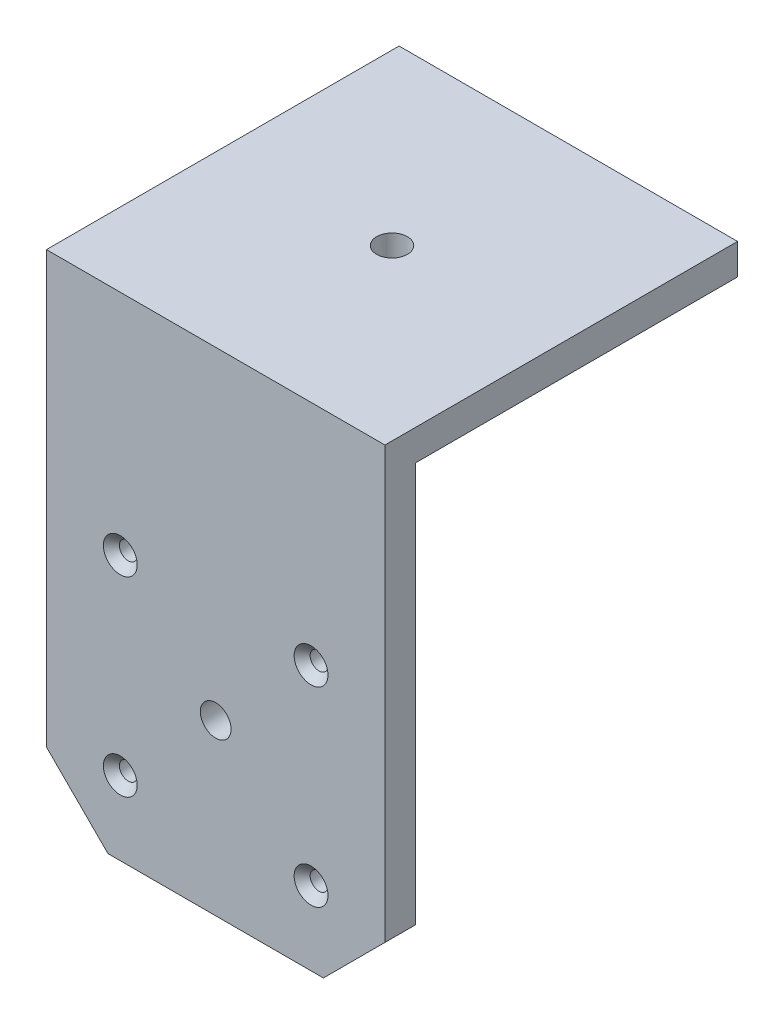
from build123d import *

# Parameters (mm, degrees)
SKETCH1_W                                         = 55
SKETCH1_H                                         = 57.3
SKETCH1_R                                         = 2.5
BOSS_EXTRUDE1_DEPTH                               = 5
SKETCH2_W                                         = 55
SKETCH2_H                                         = 5
BOSS_EXTRUDE2_DEPTH                               = 75
CUT_EXTRUDE1_REACH                                = 59.3
CUT_EXTRUDE2_REACH                                = 7
CUT_EXTRUDE3_REACH                                = 59.3
SKETCH5_R                                         = 2.5
CUT_EXTRUDE4_REACH                                = 59.3
SKETCH6_R                                         = 2.5
CUT_EXTRUDE5_REACH                                = 7
CSK_FOR_M2_5_FLAT_HEAD_MACHINE_SCREW1_D           = 2.9
CSK_FOR_M2_5_FLAT_HEAD_MACHINE_SCREW1_DEPTH       = 5
CSK_FOR_M2_5_FLAT_HEAD_MACHINE_SCREW1_CSINK_D     = 5.5
CSK_FOR_M2_5_FLAT_HEAD_MACHINE_SCREW1_CSINK_ANGLE = 90
F_6_40_TAPPED_HOLE1_D                             = 2.8702
F_6_40_TAPPED_HOLE1_DEPTH                         = 3.5
F_6_40_TAPPED_HOLE1_TIP                           = 0.862295074


with BuildPart() as part:
    # Sketch1 → Boss-Extrude1 (new body)
    with BuildSketch(Plane(origin=(0, 0, 0), x_dir=(1, 0, 0), z_dir=(0, 1, 0))):
        Rectangle(SKETCH1_W, SKETCH1_H)
        Circle(SKETCH1_R, mode=Mode.SUBTRACT)
    extrude(amount=BOSS_EXTRUDE1_DEPTH)

    # Sketch2 → Boss-Extrude2 (add)
    with BuildSketch(Plane.XZ):
        with Locations((0, 26.15)):
            Rectangle(SKETCH2_W, SKETCH2_H)
        with Locations((0, -26.15)):
            Rectangle(SKETCH2_W, SKETCH2_H)
    extrude(amount=BOSS_EXTRUDE2_DEPTH)

    # Sketch3 → Cut-Extrude1 (cut, up to next)
    with BuildSketch(Plane.XY.offset(28.65), mode=Mode.PRIVATE) as cut_extrude1_sk1:
        Polygon((-27.5, -75), (-17.5, -75), (-27.5, -65), align=None)
    cut_extrude1_tool1 = extrude(cut_extrude1_sk1.sketch, amount=-CUT_EXTRUDE1_REACH, mode=Mode.PRIVATE) & part.part
    add(cut_extrude1_tool1.solids().sort_by_distance((-24.166667, -71.666667, 28.65))[0], mode=Mode.SUBTRACT)
    # Sketch3 → Cut-Extrude1 (cut, up to next)
    with BuildSketch(Plane.XY.offset(28.65), mode=Mode.PRIVATE) as cut_extrude1_sk2:
        Polygon((27.5, -75), (27.5, -65), (17.5, -75), align=None)
    cut_extrude1_tool2 = extrude(cut_extrude1_sk2.sketch, amount=-CUT_EXTRUDE1_REACH, mode=Mode.PRIVATE) & part.part
    add(cut_extrude1_tool2.solids().sort_by_distance((24.166667, -71.666667, 28.65))[0], mode=Mode.SUBTRACT)

    # Sketch4 → Cut-Extrude2 (cut, up to next)
    with BuildSketch(Plane.XY.offset(-23.65), mode=Mode.PRIVATE) as cut_extrude2_sk1:
        Polygon((-27.5, -65), (-27.5, -75), (-17.5, -75), align=None)
    cut_extrude2_tool1 = extrude(cut_extrude2_sk1.sketch, amount=-CUT_EXTRUDE2_REACH, mode=Mode.PRIVATE) & part.part
    add(cut_extrude2_tool1.solids().sort_by_distance((-24.166667, -71.666667, -23.65))[0], mode=Mode.SUBTRACT)
    # Sketch4 → Cut-Extrude2 (cut, up to next)
    with BuildSketch(Plane.XY.offset(-23.65), mode=Mode.PRIVATE) as cut_extrude2_sk2:
        Polygon((27.5, -65), (17.5, -75), (27.5, -75), align=None)
    cut_extrude2_tool2 = extrude(cut_extrude2_sk2.sketch, amount=-CUT_EXTRUDE2_REACH, mode=Mode.PRIVATE) & part.part
    add(cut_extrude2_tool2.solids().sort_by_distance((24.166667, -71.666667, -23.65))[0], mode=Mode.SUBTRACT)

    # Sketch5 → Cut-Extrude3 (cut, up to next)
    with BuildSketch(Plane.XY.offset(28.65), mode=Mode.PRIVATE) as cut_extrude3_sk1:
        with Locations((0, -47.5)):
            Circle(SKETCH5_R)
    cut_extrude3_tool1 = extrude(cut_extrude3_sk1.sketch, amount=-CUT_EXTRUDE3_REACH, mode=Mode.PRIVATE) & part.part
    add(cut_extrude3_tool1.solids().sort_by_distance((0, -47.5, 28.65))[0], mode=Mode.SUBTRACT)

    # Sketch6 → Cut-Extrude4 (cut, up to next)
    with BuildSketch(Plane(origin=(0, 0, -28.65), x_dir=(-1, 0, 0), z_dir=(0, 0, -1)), mode=Mode.PRIVATE) as cut_extrude4_sk1:
        with Locations((0, -47.5)):
            Circle(SKETCH6_R)
    cut_extrude4_tool1 = extrude(cut_extrude4_sk1.sketch, amount=-CUT_EXTRUDE4_REACH, mode=Mode.PRIVATE) & part.part
    add(cut_extrude4_tool1.solids().sort_by_distance((0, -47.5, -28.65))[0], mode=Mode.SUBTRACT)

    # Sketch7 → Cut-Extrude5 (cut, up to next)
    with BuildSketch(Plane.XY.offset(-23.65), mode=Mode.PRIVATE) as cut_extrude5_sk1:
        Polygon((-27.5, 0), (27.5, 0), (27.5, -65), (17.5, -75), (-17.5, -75), (-27.5, -65), align=None)
    cut_extrude5_tool1 = extrude(cut_extrude5_sk1.sketch, amount=-CUT_EXTRUDE5_REACH, mode=Mode.PRIVATE) & part.part
    add(cut_extrude5_tool1.solids().sort_by_distance((0, -36.651139, -23.65))[0], mode=Mode.SUBTRACT)

    # CSK for M2.5 Flat Head Machine Screw1
    with Locations(Plane.XY.offset(28.65)):
        with Locations((-15.5, -32), (15.5, -32), (-15.5, -63), (15.5, -63)):
            CounterSinkHole(CSK_FOR_M2_5_FLAT_HEAD_MACHINE_SCREW1_D / 2, CSK_FOR_M2_5_FLAT_HEAD_MACHINE_SCREW1_CSINK_D / 2, depth=CSK_FOR_M2_5_FLAT_HEAD_MACHINE_SCREW1_DEPTH, counter_sink_angle=CSK_FOR_M2_5_FLAT_HEAD_MACHINE_SCREW1_CSINK_ANGLE)

    # #6-40 Tapped Hole1
    with Locations(Plane(origin=(0, 0, 0), x_dir=(-1, 0, 0), z_dir=(0, -1, 0))):
        with Locations((-15.5, 16.15), (15.5, 16.15)):
            Hole(F_6_40_TAPPED_HOLE1_D / 2, depth=F_6_40_TAPPED_HOLE1_DEPTH)
            with Locations((0, 0, -(F_6_40_TAPPED_HOLE1_DEPTH + F_6_40_TAPPED_HOLE1_TIP / 2))):  # 118° drill point
                Cone(0, F_6_40_TAPPED_HOLE1_D / 2, F_6_40_TAPPED_HOLE1_TIP, mode=Mode.SUBTRACT)


solid = part.part
